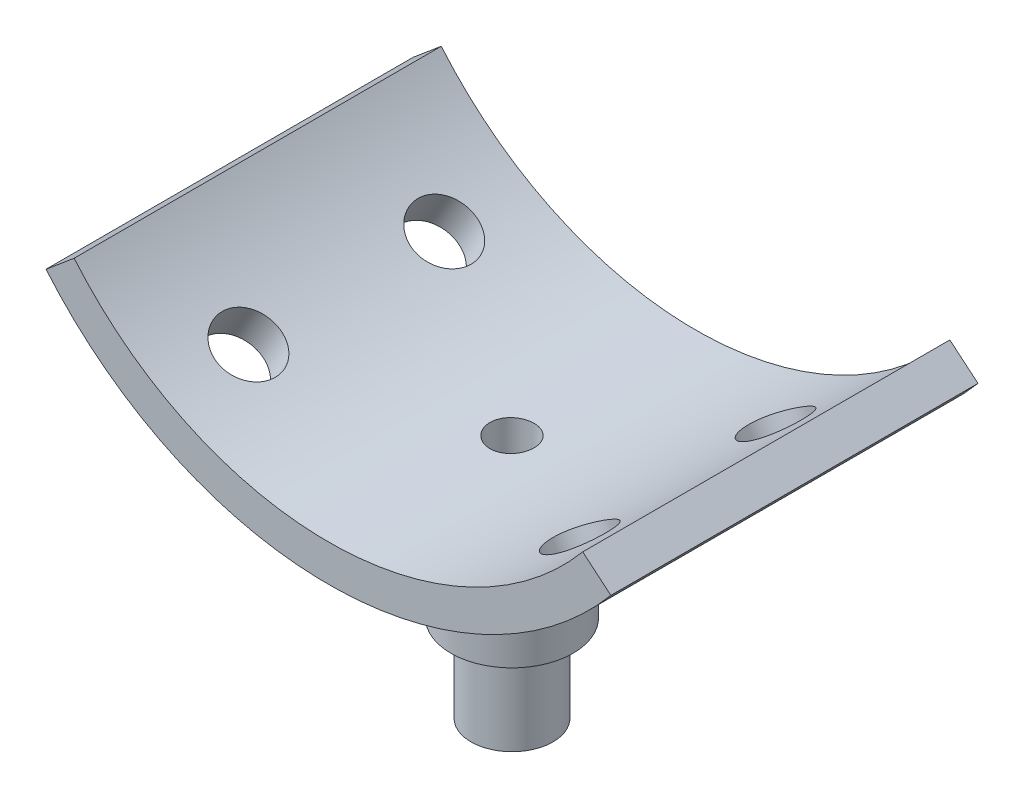
from build123d import *

# Parameters (mm, degrees)
BOSS_EXTRUDE1_DEPTH = 15
BOSS_EXTRUDE2_REACH = 24.564
SKETCH2_R           = 5
SKETCH13_R          = 2.5
CUT_EXTRUDE2_DEPTH  = 27.563859895
SKETCH14_R          = 3.35
BOSS_EXTRUDE4_DEPTH = 7.1
SKETCH15_R          = 1.8
CUT_EXTRUDE3_DEPTH  = 30.664386187


with BuildPart() as part:
    # Sketch1 → Boss-Extrude1 (new body, symmetric)
    with BuildSketch(Plane.XY):
        with BuildLine():
            Line((23.077088849, -19.363976742), (20.77895552, -17.435613913))
            ThreePointArc((20.77895552, -17.435613913), (0, -27.125), (-20.77895552, -17.435613913))
            Line((-20.77895552, -17.435613913), (-23.077088849, -19.363976742))
            ThreePointArc((-23.077088849, -19.363976742), (0, -30.125), (23.077088849, -19.363976742))
        make_face()
    extrude(amount=BOSS_EXTRUDE1_DEPTH, both=True)

    # Sketch2 → Boss-Extrude2 (add, up to next)
    with BuildSketch(Plane(origin=(0, -40, 0), x_dir=(1, 0, 0), z_dir=(0, 1, 0)), mode=Mode.PRIVATE) as boss_extrude2_sk1:
        Circle(SKETCH2_R)
    boss_extrude2_tool1 = extrude(boss_extrude2_sk1.sketch, amount=BOSS_EXTRUDE2_REACH, mode=Mode.PRIVATE) - part.part
    add(boss_extrude2_tool1.solids().sort_by_distance((0, -40, 0))[0])

    # Sketch13 → Cut-Extrude2 (cut, through all)
    with BuildSketch(Plane(origin=(15.0625, -26.089015289, 0), x_dir=(-0.866025404, -0.5, 0), z_dir=(0.5, -0.866025404, 0))):
        with Locations((0, 8)):
            Circle(SKETCH13_R)
        with Locations((0, -8)):
            Circle(SKETCH13_R)
    cut_extrude2 = extrude(amount=-CUT_EXTRUDE2_DEPTH, mode=Mode.SUBTRACT)

    # Mirror1: Cut-Extrude2 across plane
    add(cut_extrude2.mirror(Plane(origin=(0, 0, 0), x_dir=(0, 0, 1), z_dir=(1, 0, 0))), mode=Mode.SUBTRACT)

    # Sketch14 → Boss-Extrude4 (add)
    with BuildSketch(Plane.XZ.offset(40)):
        Circle(SKETCH14_R)
    extrude(amount=BOSS_EXTRUDE4_DEPTH)

    # Sketch15 → Cut-Extrude3 (cut, through all)
    with BuildSketch(Plane.XZ.offset(47.1)):
        Circle(SKETCH15_R)
    extrude(amount=-CUT_EXTRUDE3_DEPTH, mode=Mode.SUBTRACT)


solid = part.part
